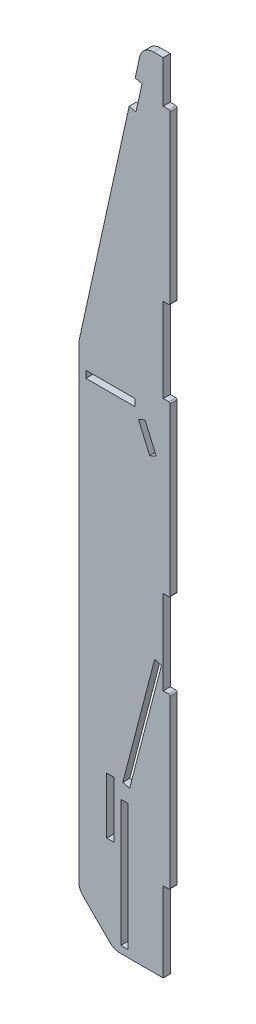
from build123d import *

# Parameters (mm, degrees)
BOSS_EXTRUDE1_DEPTH = 5
SKETCH2_W           = 5
SKETCH2_H           = 90
SKETCH2_H_2         = 40
SKETCH2_W_2         = 35
SKETCH2_H_3         = 5
CUT_EXTRUDE1_DEPTH  = 10
CUT_EXTRUDE2_DEPTH  = 10
FILLET1_R           = 1
FILLET2_R           = 10
CUT_EXTRUDE3_DEPTH  = 10


with BuildPart() as part:
    # Sketch1 → Boss-Extrude1 (new body)
    with BuildSketch(Plane.XY):
        Polygon((80, 33.22), (20, 33.22), (20, 600), (80, 600), (80, 570.05), (84.9, 570.05), (84.9, 449.95), (80, 449.95), (80, 390.05), (84.9, 390.05), (84.9, 269.95), (80, 269.95), (80, 210.05), (84.9, 210.05), (84.9, 89.95), (80, 89.95), align=None)
    extrude(amount=BOSS_EXTRUDE1_DEPTH)

    # Sketch2 → Cut-Extrude1 (cut)
    with BuildSketch(Plane.XY.offset(5)):
        Polygon((67, 370.417424305), (62.417424305, 368.417424305), (70.417424305, 350.087121525), (75, 352.087121525), align=None)
        Polygon((73.902811841, 226.418897298), (51.258042728, 139.314279557), (56.097188159, 138.056236829), (78.741957272, 225.16085457), align=None)
        with Locations((52.33914543, 83.217091399)):
            Rectangle(SKETCH2_W, SKETCH2_H)
        with Locations((42.33914543, 119.314279557)):
            Rectangle(SKETCH2_W, SKETCH2_H_2)
        with Locations((42.5, 377.5)):
            Rectangle(SKETCH2_W_2, SKETCH2_H_3)
    extrude(amount=-CUT_EXTRUDE1_DEPTH, mode=Mode.SUBTRACT)

    # Sketch3 → Cut-Extrude2 (cut)
    with BuildSketch(Plane.XY.offset(5)):
        Polygon((20, 395), (65, 600), (1.513631165, 616.08755832), align=None)
        Polygon((45, 33.22), (20, 58.22), (13.452472792, 20.556075169), align=None)
    extrude(amount=-CUT_EXTRUDE2_DEPTH, mode=Mode.SUBTRACT)

    # Fillet1
    fillet1_edges = [part.edges().sort_by_distance(p)[0] for p in [
        (84.9, 570.05, 2.5),
        (84.9, 449.95, 2.5),
        (84.9, 390.05, 2.5),
        (84.9, 269.95, 2.5),
        (84.9, 210.05, 2.5),
        (84.9, 89.95, 2.5),
    ]]
    fillet(fillet1_edges, radius=FILLET1_R)

    # Fillet2
    fillet2_edges = [part.edges().sort_by_distance(p)[0] for p in [
        (20, 395, 2.5),
        (65, 600, 2.5),
        (45, 33.22, 2.5),
        (20, 58.22, 2.5),
    ]]
    fillet(fillet2_edges, radius=FILLET2_R)

    # Sketch4 → Cut-Extrude3 (cut)
    with BuildSketch(Plane.XY.offset(5)):
        Polygon((60.059418786, 577.492907801), (64.943140501, 576.420871327), (60.654994605, 556.885984463), (55.771272889, 557.958020937), align=None)
    extrude(amount=-CUT_EXTRUDE3_DEPTH, mode=Mode.SUBTRACT)


solid = part.part
